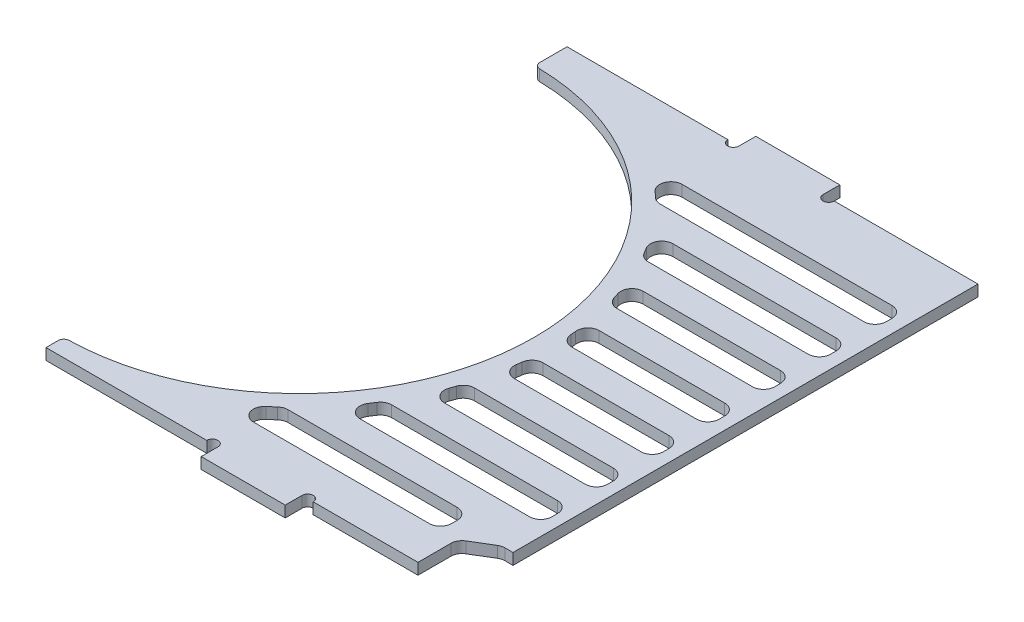
from build123d import *

# Parameters (mm, degrees)
EXTRUDE_1_DEPTH          = 2
SKETCH_3_W               = 76.4
SKETCH_3_H               = 2
EXTRUDE_2_DEPTH          = 7
CUT_EXTRUDE_1_DEPTH      = 10
EXTRUDE_4_DEPTH          = 2
PATTERN_LINEAR_2_COUNT   = 2
PATTERN_LINEAR_2_PITCH   = 32
FILLET_3_R               = 0.5
CUT_EXTRUDE_2_DEPTH      = 10
EXTRUDE_5_DEPTH          = 2
CUT_EXTRUDE_3_DEPTH      = 10
CUT_EXTRUDE_4_DEPTH      = 10
FILLET_5_R               = 2
EXTRUDE_9_DEPTH          = 2
FILLET_6_R               = 2
FILLET_7_R               = 1
SKETCH_18_W              = 76.4
SKETCH_18_H              = 2
EXTRUDE_6_DEPTH          = 2
SKETCH_19_W              = 10
SKETCH_19_H              = 10
CUT_EXTRUDE_5_DEPTH      = 3
EXTRUDE_8_DEPTH          = 2
FILLET_8_R               = 2
FILLET_9_R               = 2
SKETCH_21_W              = 3
SKETCH_21_H              = 87.342834434
CUT_EXTRUDE_6_DEPTH      = 3
CUT_EXTRUDE_7_DEPTH      = 1
CUT_EXTRUDE_7_DEPTH_BACK = 3
SKETCH_24_W              = 15
SKETCH_24_H              = 2
EXTRUDE_10_DEPTH         = 3
SKETCH_25_R              = 1
CUT_EXTRUDE_8_DEPTH      = 3


with BuildPart() as part:
    # 草图1 → 凸台-拉伸1 (new body)
    with BuildSketch(Plane(origin=(0, 0, 0), x_dir=(1, 0, 0), z_dir=(0, 1, 0))):
        with BuildLine():
            Line((-38.2, -44.69), (-38.2, -45.85))
            Line((-38.2, -45.85), (38.2, -45.85))
            Line((38.2, -45.85), (38.2, 45.85))
            Line((38.2, 45.85), (-38.2, 45.85))
            Line((-38.2, 45.85), (-38.2, 39.31))
            ThreePointArc((-38.2, 39.31), (3.8, -2.69), (-38.2, -44.69))
        make_face()
    extrude(amount=EXTRUDE_1_DEPTH)

    # 草图3 → 凸台-拉伸2 (add)
    with BuildSketch(Plane(origin=(0, 0, -45.85), x_dir=(-1, 0, 0), z_dir=(0, 0, -1))):
        with Locations((0, 1)):
            Rectangle(SKETCH_3_W, SKETCH_3_H)
    extrude(amount=EXTRUDE_2_DEPTH)

    # 草图5 → 切除-拉伸1 (cut)
    with BuildSketch(Plane(origin=(0, 2, 0), x_dir=(1, 0, 0), z_dir=(0, 1, 0))):
        Polygon((-38.2, 51.26), (38.2, 52.85), (-38.2, 52.85), align=None)
    extrude(amount=-CUT_EXTRUDE_1_DEPTH, mode=Mode.SUBTRACT)

    # 草图7 → 凸台-拉伸4 (add)
    with BuildSketch(Plane.XZ):
        Polygon((25.6, -52.587774869), (25.6, -54.754790576), (9.6, -54.754790576), (9.6, -52.254790576), align=None)
    extrude_4 = extrude(amount=-EXTRUDE_4_DEPTH)

    # 阵列(线性)2: 凸台-拉伸4 ×2
    with Locations(*[Vector(-0.999783511, 0, 0.020807013) * (i * PATTERN_LINEAR_2_PITCH) for i in range(1, PATTERN_LINEAR_2_COUNT)]):
        add(extrude_4)

    # 圆角3
    fillet_3_edges = [part.edges().sort_by_distance(p)[0] for p in [
        (25.6, 1, -54.754790576),
        (9.6, 1, -54.754790576),
        (-6.393072342, 1, -54.088966165),
        (-22.393072342, 1, -54.088966165),
    ]]
    fillet(fillet_3_edges, radius=FILLET_3_R)

    # 草图10 → 切除-拉伸2 (cut)
    with BuildSketch(Plane(origin=(0, 2, 0), x_dir=(1, 0, 0), z_dir=(0, 1, 0))):
        Polygon((-38.882265213, 53.905585721), (39.585789662, 55.538625083), (39.585789662, 48.538625083), (-38.2, 46.919784696), (-39.22769149, 52.889737929), align=None)
    extrude(amount=-CUT_EXTRUDE_2_DEPTH, mode=Mode.SUBTRACT)

    # 草图11 → 凸台-拉伸5 (add)
    with BuildSketch(Plane(origin=(0, 2, 0), x_dir=(1, 0, 0), z_dir=(0, 1, 0))):
        Polygon((-38.2, 46.919784696), (38.2, 49.509784696), (38.2, 48.509784696), align=None)
    extrude(amount=-EXTRUDE_5_DEPTH)

    # 草图13 → 切除-拉伸3 (cut)
    with BuildSketch(Plane.XZ):
        Polygon((38.2, -49.509784696), (37.7, -49.492834434), (38.2, 45.85), align=None)
    extrude(amount=-CUT_EXTRUDE_3_DEPTH, mode=Mode.SUBTRACT)

    # 草图16 → 切除-拉伸4 (cut)
    with BuildSketch(Plane.XZ):
        with BuildLine():
            ThreePointArc((-21.63159016, -39.14883119), (-26.948214114, -40.880601492), (-32.438562967, -41.939652064))
            Line((-32.438562967, -41.939652064), (32.727956442, -44.14883119))
            Line((32.727956442, -44.14883119), (32.754177605, -39.14883119))
            Line((32.754177605, -39.14883119), (-21.63159016, -39.14883119))
        make_face()
        with BuildLine():
            ThreePointArc((-6.399232266, -29.14883119), (-9.26951053, -31.777764346), (-12.35622867, -34.14883119))
            Line((-12.35622867, -34.14883119), (32.780398767, -34.14883119))
            Line((32.780398767, -34.14883119), (32.80661993, -29.14883119))
            Line((32.80661993, -29.14883119), (-6.399232266, -29.14883119))
        make_face()
        with BuildLine():
            ThreePointArc((1.145462918, -19.14883119), (-0.38438284, -21.702193399), (-2.079685213, -24.14883119))
            Line((-2.079685213, -24.14883119), (32.832841093, -24.14883119))
            Line((32.832841093, -24.14883119), (32.859062256, -19.14883119))
            Line((32.859062256, -19.14883119), (1.145462918, -19.14883119))
        make_face()
        with BuildLine():
            ThreePointArc((5.214767949, -9.14883119), (4.446089194, -11.673532869), (3.530729255, -14.14883119))
            Line((3.530729255, -14.14883119), (32.885283419, -14.14883119))
            Line((32.885283419, -14.14883119), (32.911504582, -9.14883119))
            Line((32.911504582, -9.14883119), (5.214767949, -9.14883119))
        make_face()
        with BuildLine():
            Line((32.937725745, -4.14883119), (32.963946908, 0.85116881))
            Line((32.963946908, 0.85116881), (6.762414302, 0.85116881))
            ThreePointArc((6.762414302, 0.85116881), (6.58968308, -1.65560578), (6.277301941, -4.14883119))
            Line((6.277301941, -4.14883119), (32.937725745, -4.14883119))
        make_face()
        with BuildLine():
            Line((33.016389234, 10.85116881), (6.053760559, 10.85116881))
            ThreePointArc((6.053760559, 10.85116881), (6.441352349, 8.360067057), (6.688829476, 5.85116881))
            Line((6.688829476, 5.85116881), (32.990168071, 5.85116881))
            Line((32.990168071, 5.85116881), (33.016389234, 10.85116881))
        make_face()
        with BuildLine():
            Line((33.06883156, 20.85116881), (2.97246589, 20.85116881))
            ThreePointArc((2.97246589, 20.85116881), (3.976569254, 18.378754125), (4.832355682, 15.85116881))
            Line((4.832355682, 15.85116881), (33.042610397, 15.85116881))
            Line((33.042610397, 15.85116881), (33.06883156, 20.85116881))
        make_face()
        with BuildLine():
            Line((33.121273886, 30.85116881), (-3.100875064, 30.85116881))
            ThreePointArc((-3.100875064, 30.85116881), (-1.274777634, 28.410185715), (0.381864384, 25.85116881))
            Line((0.381864384, 25.85116881), (33.095052723, 25.85116881))
            Line((33.095052723, 25.85116881), (33.121273886, 30.85116881))
        make_face()
        with BuildLine():
            Line((33.173710083, 40.85), (-14.350169812, 40.85))
            ThreePointArc((-14.350169812, 40.85), (-10.950539992, 38.501547429), (-7.780649528, 35.85116881))
            Line((-7.780649528, 35.85116881), (33.147495049, 35.85116881))
            Line((33.147495049, 35.85116881), (33.173710083, 40.85))
        make_face()
    extrude(amount=-CUT_EXTRUDE_4_DEPTH, mode=Mode.SUBTRACT)

    # 圆角5
    fillet_5_edges = [part.edges().sort_by_distance(p)[0] for p in [
        (-21.63159016, 1, -39.14883119),
        (32.754177605, 1, -39.14883119),
        (32.727956442, 1, -44.14883119),
        (-6.399232266, 1, -29.14883119),
        (32.80661993, 1, -29.14883119),
        (32.780398767, 1, -34.14883119),
        (-2.079685213, 1, -24.14883119),
        (3.530729255, 1, -14.14883119),
        (5.214767949, 1, -9.14883119),
        (32.911504582, 1, -9.14883119),
        (32.885283419, 1, -14.14883119),
        (32.937725745, 1, -4.14883119),
        (6.688829476, 1, 5.85116881),
        (33.016389234, 1, 10.85116881),
        (32.990168071, 1, 5.85116881),
        (4.832355682, 1, 15.85116881),
        (2.97246589, 1, 20.85116881),
        (0.381864384, 1, 25.85116881),
        (-3.100875064, 1, 30.85116881),
        (33.121273886, 1, 30.85116881),
        (-14.350169812, 1, 40.85),
        (33.173710083, 1, 40.85),
    ]]
    fillet(fillet_5_edges, radius=FILLET_5_R)

    # 草图23 → 凸台-拉伸9 (add)
    with BuildSketch(Plane.XZ):
        with BuildLine():
            Line((30.743661638, -39.14883119), (-21.254296123, -39.14883119))
            ThreePointArc((-21.254296123, -39.14883119), (-21.621062836, -39.182748237), (-21.975389905, -39.283349012))
            ThreePointArc((-21.975389905, -39.283349012), (-27.127035015, -40.926389654), (-32.438562967, -41.939652064))
            Line((-32.438562967, -41.939652064), (30.67101495, -44.079099797))
            ThreePointArc((30.67101495, -44.079099797), (32.125051399, -43.521859473), (32.738749569, -42.090736373))
            Line((32.738749569, -42.090736373), (32.743634136, -41.159319511))
            ThreePointArc((32.743634136, -41.159319511), (32.161578532, -39.738330684), (30.743661638, -39.14883119))
        make_face()
    extrude(amount=-EXTRUDE_9_DEPTH)

    # 圆角6
    fillet_6_edges = [part.edges().sort_by_distance(p)[0] for p in [
        (-12.35622867, 1, -34.14883119),
        (1.145462918, 1, -19.14883119),
        (32.859062256, 1, -19.14883119),
        (32.832841093, 1, -24.14883119),
        (6.277301941, 1, -4.14883119),
        (6.762414302, 1, 0.85116881),
        (32.963946908, 1, 0.85116881),
        (6.053760559, 1, 10.85116881),
        (33.06883156, 1, 20.85116881),
        (33.042610397, 1, 15.85116881),
        (33.095052723, 1, 25.85116881),
        (-7.780649528, 1, 35.85116881),
        (33.147495049, 1, 35.85116881),
    ]]
    fillet(fillet_6_edges, radius=FILLET_6_R)

    # 圆角7
    fillet_7_edges = [part.edges().sort_by_distance(p)[0] for p in [
        (-38.2, 1, 44.69),
        (-38.2, 1, -39.31),
        (-38.2, 1, -46.919784696),
    ]]
    fillet(fillet_7_edges, radius=FILLET_7_R)

    # 草图18 → 凸台-拉伸6 (add)
    with BuildSketch(Plane.XY.offset(45.85)):
        with Locations((0, 1)):
            Rectangle(SKETCH_18_W, SKETCH_18_H)
    extrude(amount=EXTRUDE_6_DEPTH)

    # 草图19 → 切除-拉伸5 (cut, through all)
    with BuildSketch(Plane(origin=(0, 2, 0), x_dir=(1, 0, 0), z_dir=(0, 1, 0))):
        with Locations((33.2, -42.85)):
            Rectangle(SKETCH_19_W, SKETCH_19_H)
    extrude(amount=-CUT_EXTRUDE_5_DEPTH, mode=Mode.SUBTRACT)

    # 草图20 → 凸台-拉伸8 (add)
    with BuildSketch(Plane(origin=(0, 2, 0), x_dir=(1, 0, 0), z_dir=(0, 1, 0))):
        Polygon((25.2, -35.85116881), (33.157977385, -35.85116881), (33.157977385, -37.85), (28.2, -40.85), (25.2, -40.85), align=None)
    extrude(amount=-EXTRUDE_8_DEPTH)

    # 圆角8
    fillet_8_edges = [part.edges().sort_by_distance(p)[0] for p in [
        (25.2, 1, 40.85),
        (25.2, 1, 35.85116881),
    ]]
    fillet(fillet_8_edges, radius=FILLET_8_R)

    # 圆角9
    fillet_9_edges = [part.edges().sort_by_distance(p)[0] for p in [
        (33.157977385, 1, 37.85),
        (28.2, 1, 40.85),
    ]]
    fillet(fillet_9_edges, radius=FILLET_9_R)

    # 草图21 → 切除-拉伸6 (cut, through all)
    with BuildSketch(Plane.XZ):
        with Locations((36.658046139, -5.821417217)):
            Rectangle(SKETCH_21_W, SKETCH_21_H)
    extrude(amount=-CUT_EXTRUDE_6_DEPTH, mode=Mode.SUBTRACT)

    # 草图22 → 切除-拉伸7 (cut, two sides)
    with BuildSketch(Plane.XZ) as cut_extrude_7_sk:
        Polygon((-290.579437235, -45.15), (-39.244125604, -45.15), (60.755874396, -45.15), (60.755874396, -51.15), (-39.244125604, -51.15), (-39.244125604, -47.15), (-39.244125604, 204.185311631), (314.77499341, -152.673510404), (63.439681778, -402.008822036), align=None)
    extrude(amount=CUT_EXTRUDE_7_DEPTH, mode=Mode.SUBTRACT)
    extrude(cut_extrude_7_sk.sketch, amount=-CUT_EXTRUDE_7_DEPTH_BACK, mode=Mode.SUBTRACT)

    # 草图24 → 凸台-拉伸10 (add)
    with BuildSketch(Plane(origin=(0, 0, -45.15), x_dir=(-1, 0, 0), z_dir=(0, 0, -1))):
        with Locations((0, 1)):
            Rectangle(SKETCH_24_W, SKETCH_24_H)
    extrude_10 = extrude(amount=EXTRUDE_10_DEPTH)

    # 草图25 → 切除-拉伸8 (cut, through all)
    with BuildSketch(Plane(origin=(0, 2, 0), x_dir=(1, 0, 0), z_dir=(0, 1, 0))):
        with Locations((-8.5, 45.15)):
            Circle(SKETCH_25_R)
        with Locations((8.5, 45.15)):
            Circle(SKETCH_25_R)
    cut_extrude_8 = extrude(amount=-CUT_EXTRUDE_8_DEPTH, mode=Mode.SUBTRACT)

    # 镜向1: 凸台-拉伸10, 切除-拉伸8 across plane
    add(extrude_10.mirror(Plane.XY.offset(1.35)))
    add(cut_extrude_8.mirror(Plane.XY.offset(1.35)), mode=Mode.SUBTRACT)


solid = part.part
